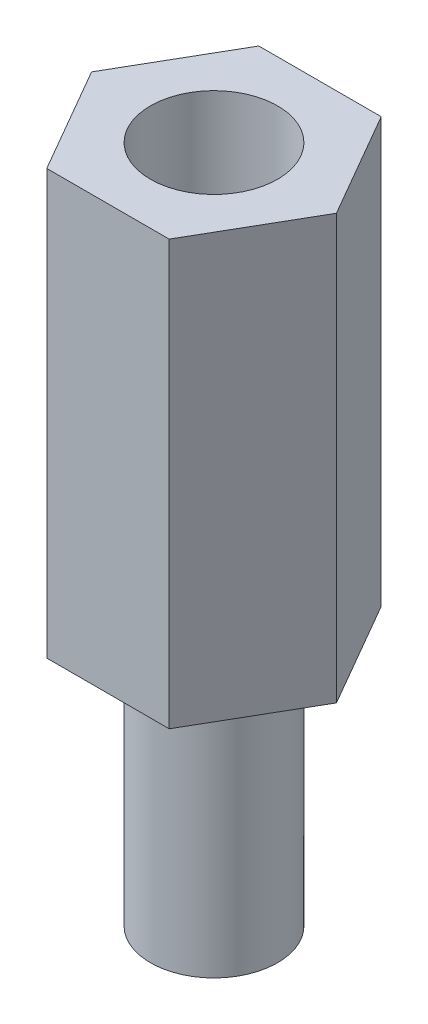
from build123d import *

# Parameters (mm, degrees)
CROQUIS1_R              = 1.5
SALIENTE_EXTRUIR1_DEPTH = 10
CROQUIS2_R              = 1.5
SALIENTE_EXTRUIR2_DEPTH = 6


with BuildPart() as part:
    # Croquis1 → Saliente-Extruir1 (new body)
    with BuildSketch(Plane(origin=(0, 0, 0), x_dir=(1, 0, 0), z_dir=(0, 1, 0))):
        Polygon((1.443375673, -2.5), (2.886751346, 0), (1.443375673, 2.5), (-1.443375673, 2.5), (-2.886751346, 0), (-1.443375673, -2.5), align=None)
        Circle(CROQUIS1_R, mode=Mode.SUBTRACT)
    extrude(amount=SALIENTE_EXTRUIR1_DEPTH)


with BuildPart() as body_2:
    # Croquis2 → Saliente-Extruir2 (new body)
    with BuildSketch(Plane.XZ):
        Circle(CROQUIS2_R)
    extrude(amount=SALIENTE_EXTRUIR2_DEPTH)


solid = Compound([part.part, body_2.part])
